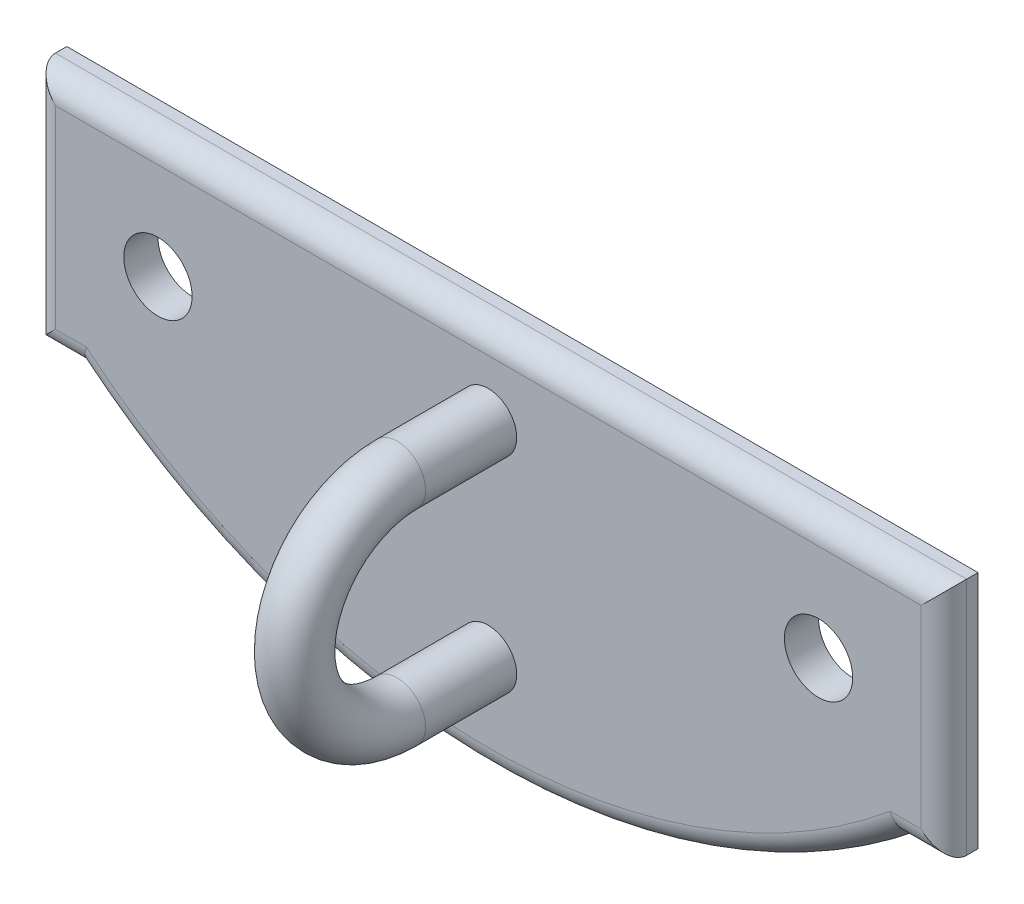
from build123d import *

# Parameters (mm, degrees)
BOSS_EXTRUDE1_DEPTH = 1.5
SKETCH2_R           = 1.5
CUT_EXTRUDE1_DEPTH  = 1.5
SKETCH3_R           = 1.25
FILLET1_R           = 1


with BuildPart() as part:
    # Sketch1 → Boss-Extrude1 (new body)
    with BuildSketch(Plane.XY):
        with BuildLine():
            Line((0, 0), (20, 0))
            Line((20, 0), (20, -10.5))
            Line((20, -10.5), (18, -10.5))
            ThreePointArc((18, -10.5), (0, -16.9094223), (-18, -10.5))
            Line((-18, -10.5), (-20, -10.5))
            Line((-20, -10.5), (-20, 0))
            Line((-20, 0), (0, 0))
        make_face()
    extrude(amount=BOSS_EXTRUDE1_DEPTH)

    # Sketch2 → Cut-Extrude1 (cut)
    with BuildSketch(Plane.XY.offset(1.5)):
        with Locations((-14.5, -5.25)):
            Circle(SKETCH2_R)
        with Locations((14.5, -5.25)):
            Circle(SKETCH2_R)
    extrude(amount=-CUT_EXTRUDE1_DEPTH, mode=Mode.SUBTRACT)

    # Sweep2: sweep along a path in Sketch4
    with BuildLine(Plane(origin=(0, 0, 0), x_dir=(0, 0, -1), z_dir=(1, 0, 0))) as sweep2_path:
        Line((-1.5, -3.5), (-5.5, -3.5))
        ThreePointArc((-5.5, -3.5), (-10, -8), (-5.5, -12.5))
        Line((-5.5, -12.5), (-1.5, -12.5))
    # Sketch3 → Sweep2 (sweep)
    with BuildSketch(Plane.XY.offset(1.5)):
        with Locations((0, -12.5)):
            Circle(SKETCH3_R)
    sweep(path=sweep2_path.line)

    # Fillet1
    fillet1_edges = [part.edges().sort_by_distance(p)[0] for p in [
        (-19, -10.5, 1.5),
        (0, -16.9094223, 1.5),
        (19, -10.5, 1.5),
        (20, -5.25, 1.5),
        (0, 0, 1.5),
        (-20, -5.25, 1.5),
    ]]
    fillet(fillet1_edges, radius=FILLET1_R)


solid = part.part
